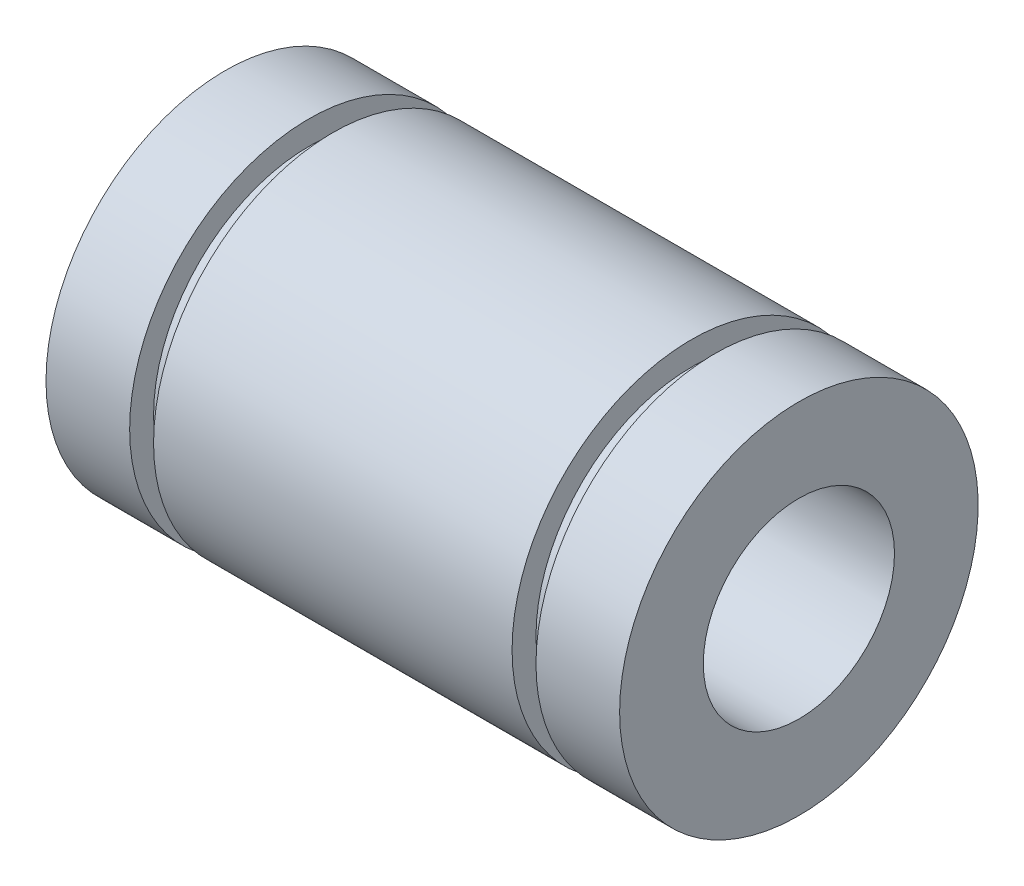
from build123d import *


with BuildPart() as part:
    # Croquis4 → Revolución1 (revolve)
    with BuildSketch(Plane.XY):
        Polygon((0, 4), (24, 4), (24, 7.5), (20.5, 7.5), (20.5, 6.5), (19.5, 6.5), (19.5, 7.5), (4.5, 7.5), (4.5, 6.5), (3.5, 6.5), (3.5, 7.5), (0, 7.5), align=None)
    revolve(axis=Axis((0, 0, 0), (1, 0, 0)))


solid = part.part
